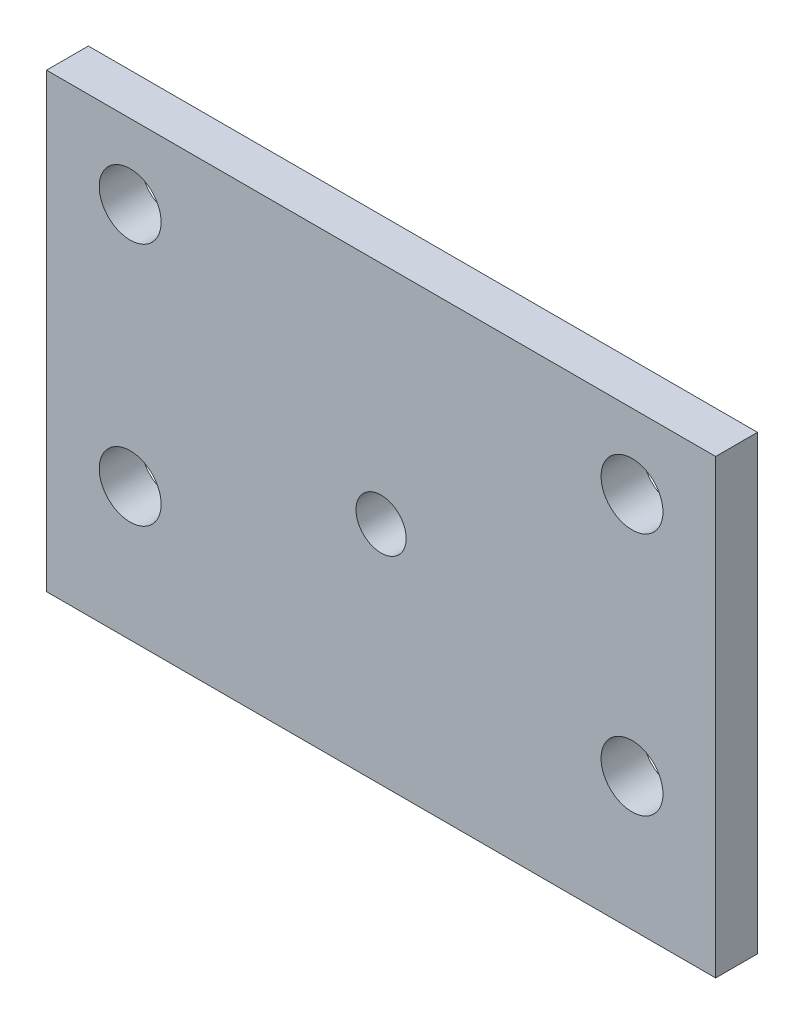
from build123d import *

# Parameters (mm, degrees)
SKETCH1_W           = 50.8
SKETCH1_H           = 34.29
SKETCH1_R           = 2.3495
SKETCH1_R_2         = 1.905
BOSS_EXTRUDE1_DEPTH = 3.175


with BuildPart() as part:
    # Sketch1 → Boss-Extrude1 (new body)
    with BuildSketch(Plane.XY):
        Rectangle(SKETCH1_W, SKETCH1_H)
        with Locations((19.05, -7.0485)):
            Circle(SKETCH1_R, mode=Mode.SUBTRACT)
        with Locations((19.05, 11.4935)):
            Circle(SKETCH1_R, mode=Mode.SUBTRACT)
        with Locations((-19.05, 11.4935)):
            Circle(SKETCH1_R, mode=Mode.SUBTRACT)
        with Locations((-19.05, -7.0485)):
            Circle(SKETCH1_R, mode=Mode.SUBTRACT)
        Circle(SKETCH1_R_2, mode=Mode.SUBTRACT)
    extrude(amount=BOSS_EXTRUDE1_DEPTH)


solid = part.part
